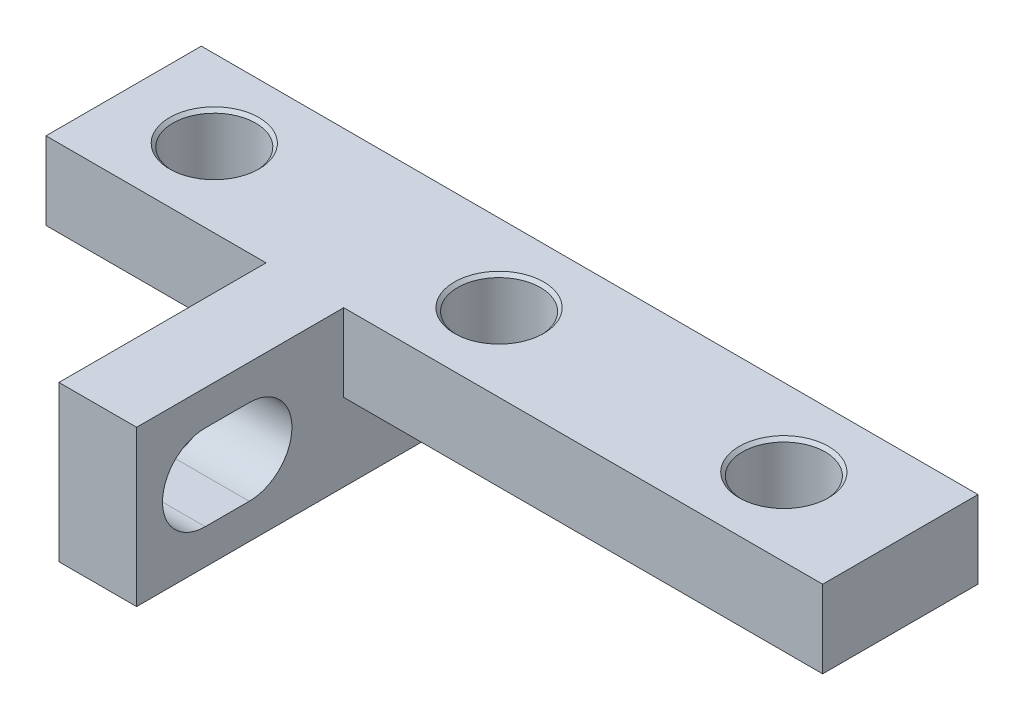
from build123d import *

# Parameters (mm, degrees)
EXTRUDE_1_DEPTH            = 14
SKETCH_2_W                 = 10
SKETCH_2_H                 = 3
SKETCH_2_W_2               = 3
SKETCH_2_H_2               = 19
CUT_EXTRUDE_1_DEPTH        = 15
SKETCH_3_W                 = 8.5
SKETCH_3_H                 = 3
SKETCH_3_W_2               = 18.5
CUT_EXTRUDE_3_DEPTH        = 8
HOLE_WIZARD_M31_AT_2_COUNT = 2
HOLE_WIZARD_M31_AT_2_PITCH = 22
HOLE_WIZARD_M31_AT_3_COUNT = 2
HOLE_WIZARD_M31_AT_3_PITCH = 11
CUT_EXTRUDE_4_REACH        = 13.5


with BuildPart() as part:
    # Эскиз1 → Бобышка-Вытянуть1 (new body)
    with BuildSketch(Plane.XY):
        Polygon((-1.5, 0), (-1.5, 22), (-20, 22), (-20, 25), (20, 25), (20, 22), (1.5, 22), (1.5, 0), align=None)
    extrude(amount=EXTRUDE_1_DEPTH)

    # Эскиз2 → Вырез-Вытянуть1 (cut, through all)
    with BuildSketch(Plane.XY.offset(14)):
        with Locations((-15, 23.5)):
            Rectangle(SKETCH_2_W, SKETCH_2_H)
        with Locations((0, 9.5)):
            Rectangle(SKETCH_2_W_2, SKETCH_2_H_2)
    extrude(amount=-CUT_EXTRUDE_1_DEPTH, mode=Mode.SUBTRACT)

    # Эскиз3 → Вырез-Вытянуть3 (cut)
    with BuildSketch(Plane.XY.offset(14)):
        with Locations((-5.75, 23.5)):
            Rectangle(SKETCH_3_W, SKETCH_3_H)
        with Locations((10.75, 23.5)):
            Rectangle(SKETCH_3_W_2, SKETCH_3_H)
    extrude(amount=-CUT_EXTRUDE_3_DEPTH, mode=Mode.SUBTRACT)

    # Эскиз4 → Отверстие с зазором M31 (revolve, cut)
    with BuildSketch(Plane(origin=(-6.5, 22, 3), x_dir=(0, 0, -1), z_dir=(1, 0, 0))):
        Polygon((0, 0), (0, 3), (1.725, 3), (1.6, 2.875), (1.6, 0.125), (1.725, 0), align=None)
    hole_wizard_m31 = revolve(axis=Axis((-6.5, 15.65, 3), (0, 1, 0)), mode=Mode.SUBTRACT)

    # Отверстие с зазором M31 at 2: Отверстие с зазором M31 ×2
    with Locations(*[(i * HOLE_WIZARD_M31_AT_2_PITCH, 0, 0) for i in range(1, HOLE_WIZARD_M31_AT_2_COUNT)]):
        add(hole_wizard_m31, mode=Mode.SUBTRACT)

    # Отверстие с зазором M31 at 3: Отверстие с зазором M31 ×2
    with Locations(*[(i * HOLE_WIZARD_M31_AT_3_PITCH, 0, 0) for i in range(1, HOLE_WIZARD_M31_AT_3_COUNT)]):
        add(hole_wizard_m31, mode=Mode.SUBTRACT)

    # Эскиз6 → Вырез-Вытянуть4 (cut, up to next)
    with BuildSketch(Plane(origin=(1.5, 0, 0), x_dir=(0, 0, -1), z_dir=(1, 0, 0)), mode=Mode.PRIVATE) as cut_extrude_4_sk1:
        with BuildLine():
            Line((-11.35, 23.65), (-9.65, 23.65))
            ThreePointArc((-9.65, 23.65), (-8, 22), (-9.65, 20.35))
            Line((-9.65, 20.35), (-11.35, 20.35))
            ThreePointArc((-11.35, 20.35), (-13, 22), (-11.35, 23.65))
        make_face()
    cut_extrude_4_tool1 = extrude(cut_extrude_4_sk1.sketch, amount=-CUT_EXTRUDE_4_REACH, mode=Mode.PRIVATE) & part.part
    add(cut_extrude_4_tool1.solids().sort_by_distance((1.5, 22, 10.5))[0], mode=Mode.SUBTRACT)


solid = part.part
